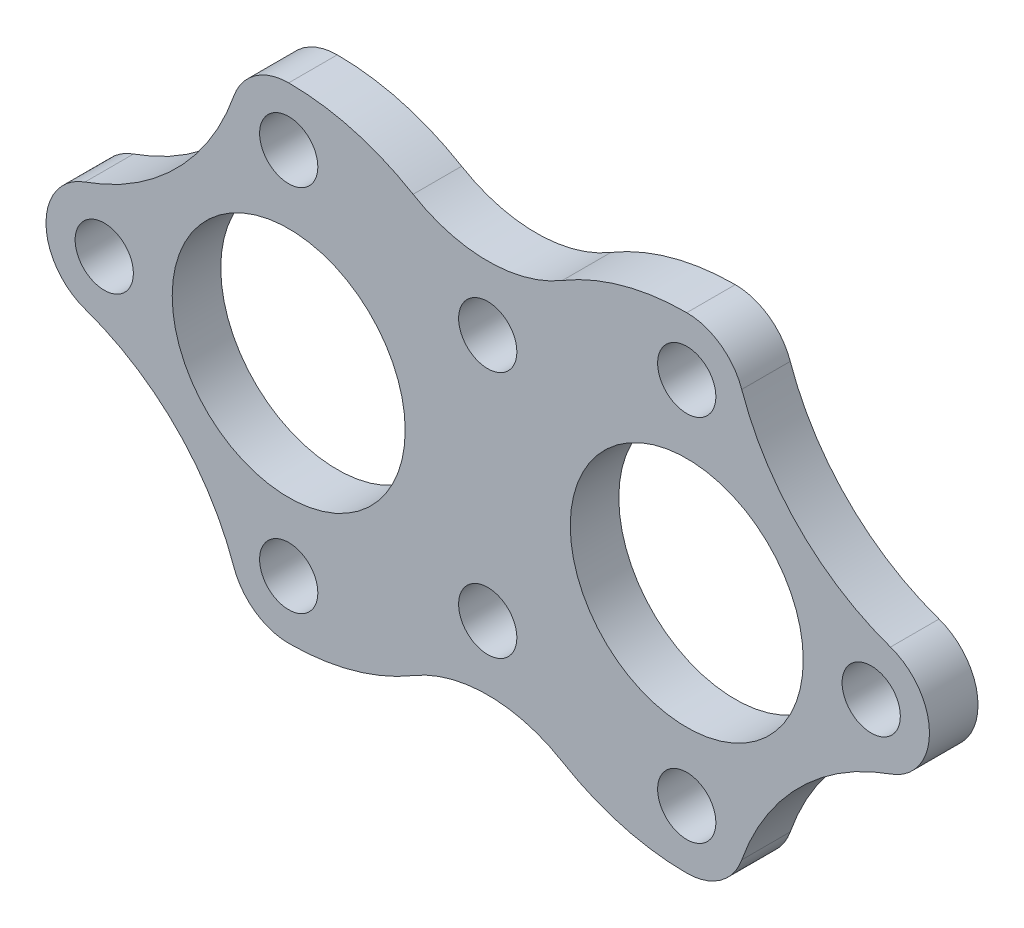
from build123d import *

# Parameters (mm, degrees)
SKETCH_1_R      = 6
SKETCH_1_R_2    = 24
EXTRUDE_1_DEPTH = 10


with BuildPart() as part:
    # Эскиз1 → Бобышка-Вытянуть1 (new body)
    with BuildSketch(Plane.XY):
        with BuildLine():
            ThreePointArc((-41, 50), (-27.709365364, 48.201234745), (-15.375, 42.934361239))
            ThreePointArc((-15.375, 42.934361239), (0, 38.694977982), (15.375, 42.934361239))
            ThreePointArc((15.375, 42.934361239), (27.709365364, 48.201234745), (41, 50))
            ThreePointArc((41, 50), (47.941363325, 47.78864011), (52.324417909, 41.969579199))
            ThreePointArc((52.324417909, 41.969579199), (64.154153471, 23.154153471), (82.969579199, 11.324417909))
            ThreePointArc((82.969579199, 11.324417909), (91, 0), (82.969579199, -11.324417909))
            ThreePointArc((82.969579199, -11.324417909), (64.154153471, -23.154153471), (52.324417909, -41.969579199))
            ThreePointArc((52.324417909, -41.969579199), (47.941363325, -47.78864011), (41, -50))
            ThreePointArc((41, -50), (27.709365364, -48.201234745), (15.375, -42.934361239))
            ThreePointArc((15.375, -42.934361239), (0, -38.694977982), (-15.375, -42.934361239))
            ThreePointArc((-15.375, -42.934361239), (-27.709365364, -48.201234745), (-41, -50))
            ThreePointArc((-41, -50), (-47.941363325, -47.78864011), (-52.324417909, -41.969579199))
            ThreePointArc((-52.324417909, -41.969579199), (-64.154153471, -23.154153471), (-82.969579199, -11.324417909))
            ThreePointArc((-82.969579199, -11.324417909), (-91, 0), (-82.969579199, 11.324417909))
            ThreePointArc((-82.969579199, 11.324417909), (-64.154153471, 23.154153471), (-52.324417909, 41.969579199))
            ThreePointArc((-52.324417909, 41.969579199), (-47.941363325, 47.78864011), (-41, 50))
        make_face()
        with Locations((-79, 0)):
            Circle(SKETCH_1_R, mode=Mode.SUBTRACT)
        with Locations((-41, 0)):
            Circle(SKETCH_1_R_2, mode=Mode.SUBTRACT)
        with Locations((41, 0)):
            Circle(SKETCH_1_R_2, mode=Mode.SUBTRACT)
        with Locations((79, 0)):
            Circle(SKETCH_1_R, mode=Mode.SUBTRACT)
        with Locations((41, -38)):
            Circle(SKETCH_1_R, mode=Mode.SUBTRACT)
        with Locations((41, 38)):
            Circle(SKETCH_1_R, mode=Mode.SUBTRACT)
        with Locations((0, 25.5)):
            Circle(SKETCH_1_R, mode=Mode.SUBTRACT)
        with Locations((0, -25.5)):
            Circle(SKETCH_1_R, mode=Mode.SUBTRACT)
        with Locations((-41, -38)):
            Circle(SKETCH_1_R, mode=Mode.SUBTRACT)
        with Locations((-41, 38)):
            Circle(SKETCH_1_R, mode=Mode.SUBTRACT)
    extrude(amount=EXTRUDE_1_DEPTH)


solid = part.part
